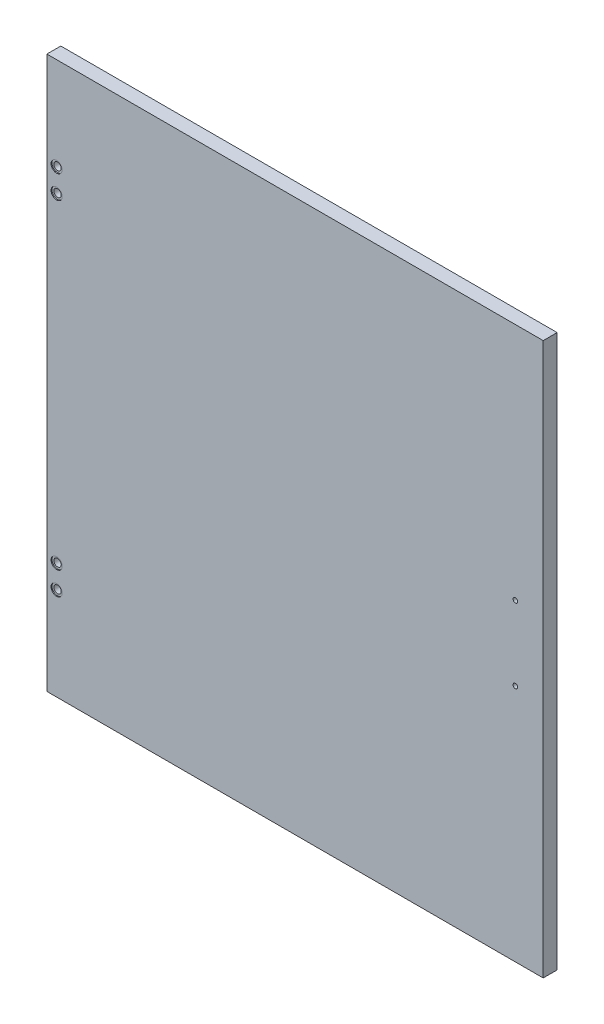
from build123d import *

# Parameters (mm, degrees)
SKETCH_1_W          = 535
SKETCH_1_H          = 595
EXTRUDE_1_DEPTH     = 15
SKETCH_2_R          = 4
CUT_EXTRUDE_2_DEPTH = 401.359213707
SKETCH_3_R          = 6
CUT_EXTRUDE_4_DEPTH = 1
SKETCH_4_R          = 2.5
CUT_EXTRUDE_5_DEPTH = 401.359213707
SKETCH_5_R          = 2
CUT_EXTRUDE_6_DEPTH = 9


with BuildPart() as part:
    # ｽｹｯﾁ1 → ﾎﾞｽ - 押し出し1 (new body)
    with BuildSketch(Plane.XY):
        Rectangle(SKETCH_1_W, SKETCH_1_H)
    extrude(amount=EXTRUDE_1_DEPTH)

    # ｽｹｯﾁ2 → ｶｯﾄ - 押し出し2 (cut, through all)
    with BuildSketch(Plane.XY.offset(15)):
        with Locations((-257, 197.5)):
            Circle(SKETCH_2_R)
        with Locations((-257, 172.5)):
            Circle(SKETCH_2_R)
    cut_extrude_2 = extrude(amount=-CUT_EXTRUDE_2_DEPTH, mode=Mode.SUBTRACT)

    # ﾐﾗｰ2: ｶｯﾄ - 押し出し2 across plane
    add(cut_extrude_2.mirror(Plane.ZX), mode=Mode.SUBTRACT)

    # ｽｹｯﾁ3 → ｶｯﾄ - 押し出し4 (cut)
    with BuildSketch(Plane.XY.offset(15)):
        with Locations((-257, 197.5)):
            Circle(SKETCH_3_R)
        with Locations((-257, 172.5)):
            Circle(SKETCH_3_R)
    cut_extrude_4 = extrude(amount=-CUT_EXTRUDE_4_DEPTH, mode=Mode.SUBTRACT)

    # ﾐﾗｰ4: ｶｯﾄ - 押し出し4 across plane
    add(cut_extrude_4.mirror(Plane.ZX), mode=Mode.SUBTRACT)

    # ｽｹｯﾁ4 → ｶｯﾄ - 押し出し5 (cut, through all)
    with BuildSketch(Plane.XY.offset(15)):
        with Locations((237.5, 40)):
            Circle(SKETCH_4_R)
        with Locations((237.5, -40)):
            Circle(SKETCH_4_R)
    extrude(amount=-CUT_EXTRUDE_5_DEPTH, mode=Mode.SUBTRACT)

    # ｽｹｯﾁ5 → ｶｯﾄ - 押し出し6 (cut)
    with BuildSketch(Plane(origin=(0, 0, 0), x_dir=(-1, 0, 0), z_dir=(0, 0, -1))):
        with Locations((-260, 188.5)):
            Circle(SKETCH_5_R)
        with Locations((-260, 176.5)):
            Circle(SKETCH_5_R)
    cut_extrude_6 = extrude(amount=-CUT_EXTRUDE_6_DEPTH, mode=Mode.SUBTRACT)

    # ﾐﾗｰ5: ｶｯﾄ - 押し出し6 across plane
    add(cut_extrude_6.mirror(Plane.ZX), mode=Mode.SUBTRACT)


solid = part.part
